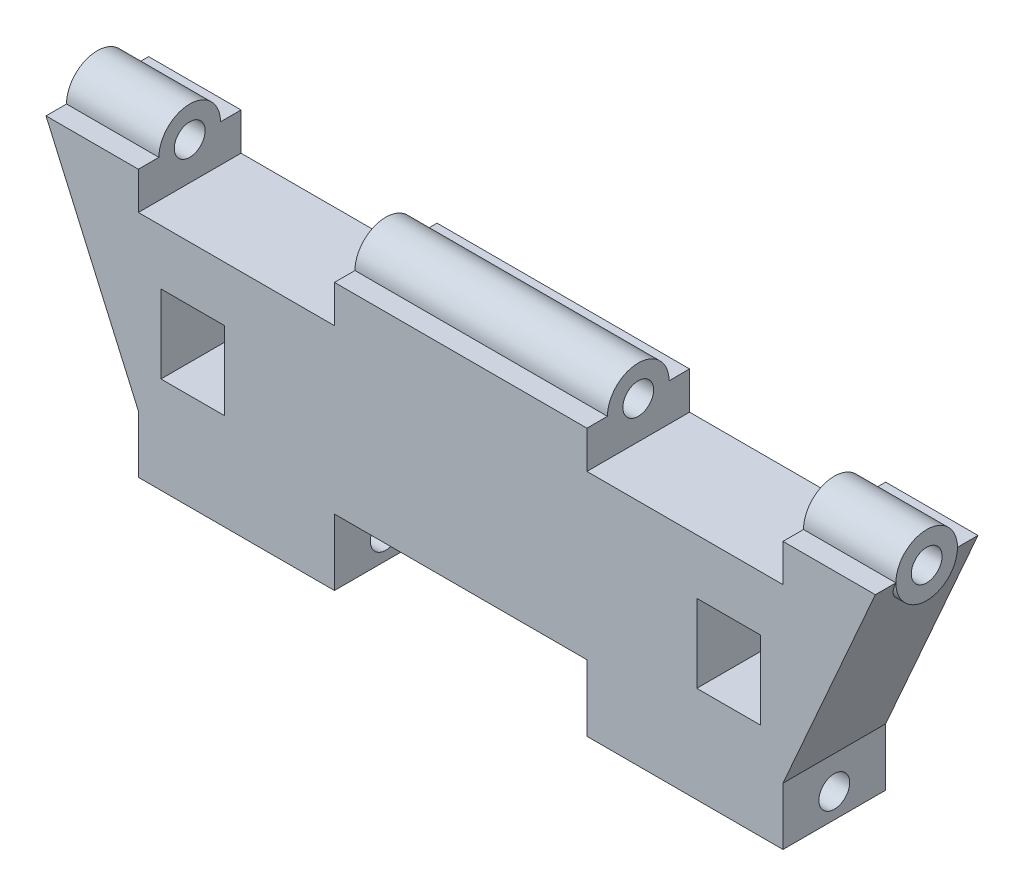
from build123d import *

# Parameters (mm, degrees)
SKETCH_1_W           = 31.4
SKETCH_1_H           = 10
SKETCH_1_H_2         = 3
EXTRUDE_1_DEPTH      = 5
SKETCH_2_W           = 3.1
SKETCH_2_H           = 3.8
CUT_EXTRUDE_1_DEPTH  = 6
SKETCH_3_R           = 1.5
EXTRUDE_2_DEPTH      = 20.2
EXTRUDE_2_DEPTH_BACK = 20.2
SKETCH_5_W           = 9.55
SKETCH_5_H           = 3.6506089
SKETCH_5_W_2         = 12.3
SKETCH_5_H_2         = 6.45906725
CUT_EXTRUDE_2_DEPTH  = 5
SKETCH_6_R           = 0.75
CUT_EXTRUDE_3_DEPTH  = 41.4


with BuildPart() as part:
    # 草图1 → 凸台-拉伸1 (new body)
    with BuildSketch(Plane.XY):
        Rectangle(SKETCH_1_W, SKETCH_1_H)
        with Locations((0, 6.5)):
            Rectangle(SKETCH_1_W, SKETCH_1_H_2)
        Polygon((-15.7, 8), (-20.2, 8), (-15.7, -2.2), (-15.7, 5), align=None)
        Polygon((20.2, 8), (15.7, 8), (15.7, 5), (15.7, -2.2), align=None)
    extrude(amount=EXTRUDE_1_DEPTH)

    # 草图2 → 切除-拉伸1 (cut, through all)
    with BuildSketch(Plane.XY.offset(5)):
        with Locations((-13.05, 1.6)):
            Rectangle(SKETCH_2_W, SKETCH_2_H)
        with Locations((13.05, 1.6)):
            Rectangle(SKETCH_2_W, SKETCH_2_H)
    extrude(amount=-CUT_EXTRUDE_1_DEPTH, mode=Mode.SUBTRACT)

    # 草图3 → 凸台-拉伸2 (add, two sides)
    with BuildSketch(Plane(origin=(0, 0, 0), x_dir=(0, 0, -1), z_dir=(1, 0, 0))) as extrude_2_sk:
        with Locations((-2.5, 8)):
            Circle(SKETCH_3_R)
    extrude(amount=EXTRUDE_2_DEPTH)
    extrude(extrude_2_sk.sketch, amount=-EXTRUDE_2_DEPTH_BACK)

    # 草图5 → 切除-拉伸2 (cut)
    with BuildSketch(Plane.XY.offset(5)):
        with Locations((-10.925, 8)):
            Rectangle(SKETCH_5_W, SKETCH_5_H)
        with Locations((10.925, 8)):
            Rectangle(SKETCH_5_W, SKETCH_5_H)
        with Locations((0, -5)):
            Rectangle(SKETCH_5_W_2, SKETCH_5_H_2)
    extrude(amount=-CUT_EXTRUDE_2_DEPTH, mode=Mode.SUBTRACT)

    # 草图6 → 切除-拉伸3 (cut, through all)
    with BuildSketch(Plane.ZY.offset(20.2)):
        with Locations((2.5, 8)):
            Circle(SKETCH_6_R)
        with Locations((2.5, -3.8)):
            Circle(SKETCH_6_R)
    extrude(amount=-CUT_EXTRUDE_3_DEPTH, mode=Mode.SUBTRACT)


solid = part.part
